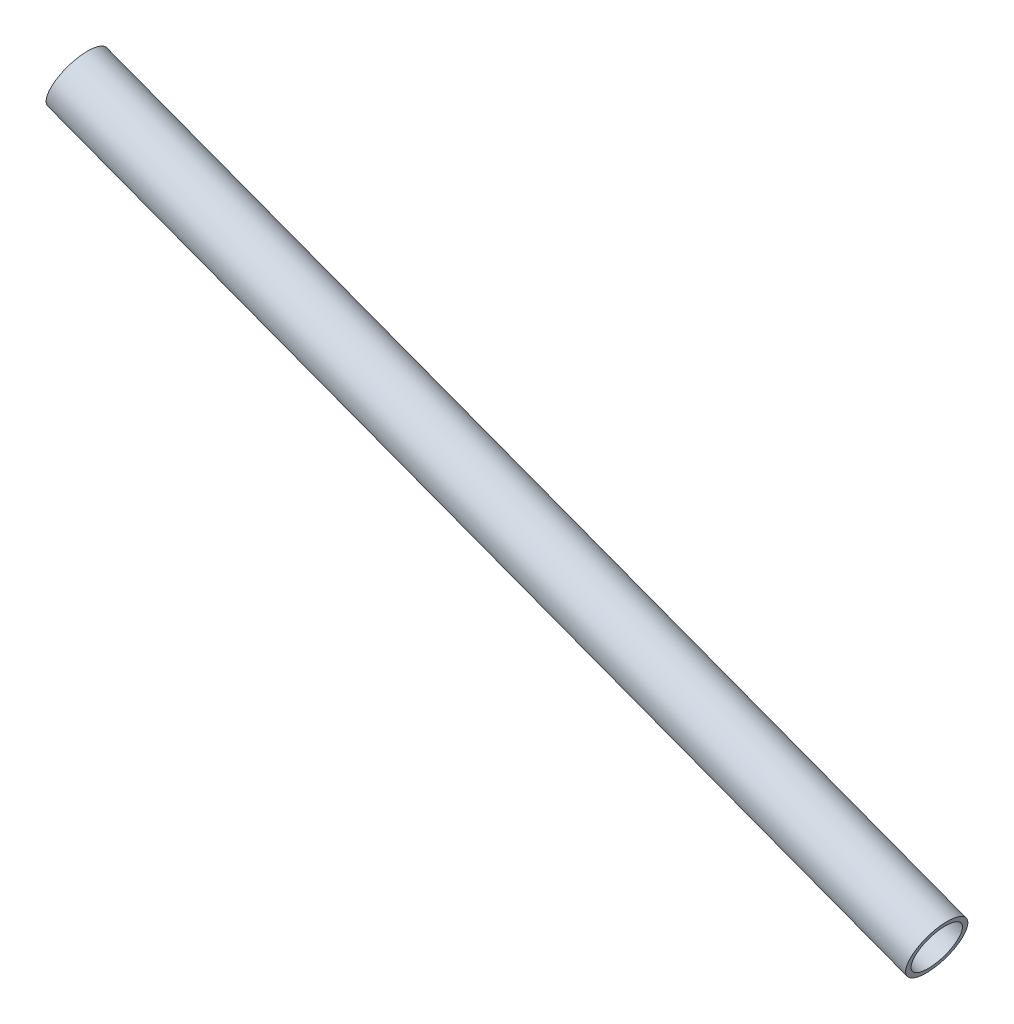
from build123d import *


with BuildPart() as part:
    # Sketch1 → Revolve1 (revolve)
    with BuildSketch(Plane.XY):
        Polygon((-239.909548224, -1718.756521714), (-518.648306478, -1613.699323346), (-518.066026317, -1612.154412082), (-239.327268063, -1717.21161045), align=None)
    revolve(axis=Axis((-236.550239601, -1709.843572114, 0), (-0.93574274, 0.35268332, 0)))


solid = part.part
